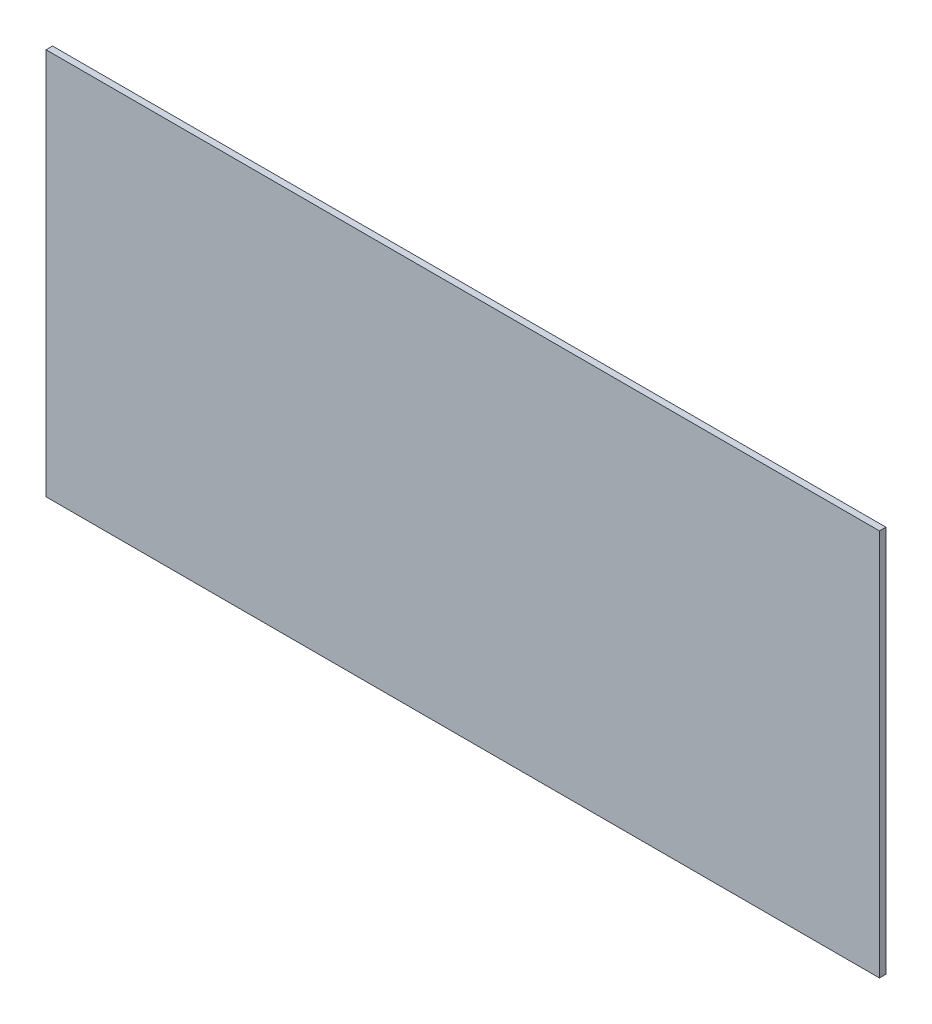
from build123d import *

# Parameters (mm, degrees)
SKETCH1_W           = 579
SKETCH1_H           = 269
BOSS_EXTRUDE1_DEPTH = 2.2479


with BuildPart() as part:
    # Sketch1 → Boss-Extrude1 (new body, symmetric)
    with BuildSketch(Plane.XY):
        Rectangle(SKETCH1_W, SKETCH1_H)
    extrude(amount=BOSS_EXTRUDE1_DEPTH, both=True)


solid = part.part
